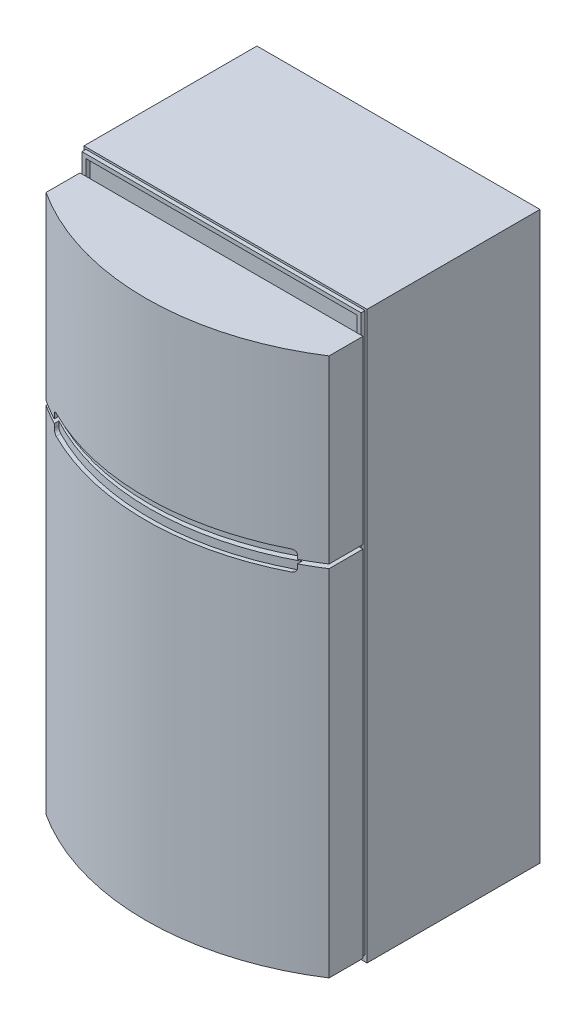
from build123d import *

# Parameters (mm, degrees)
SKETCH1_W               = 900
SKETCH1_H               = 550
BOSS_EXTRUDE1_DEPTH     = 1800
BOSS_EXTRUDE2_START     = 19.05
BOSS_EXTRUDE2_DEPTH     = 1712.976
SKETCH3_W               = 900
SKETCH3_H               = 12.7
CUT_EXTRUDE1_DEPTH      = 1712.976
CUT_EXTRUDE2_REACH      = 2023.869
CUT_EXTRUDE2_END_RADIUS = 816.026540559
SKETCH5_W               = 887.3
SKETCH5_H               = 1774.6
SKETCH5_W_2             = 861.9
SKETCH5_H_2             = 1749.2
EXTRUDE_THIN1_DEPTH     = 12.7
CUT_EXTRUDE3_DEPTH      = 1936.20024806


with BuildPart() as part:
    # Sketch1 → Boss-Extrude1 (new body)
    with BuildSketch(Plane(origin=(0, 0, 0), x_dir=(1, 0, 0), z_dir=(0, 1, 0))):
        Rectangle(SKETCH1_W, SKETCH1_H)
    extrude(amount=BOSS_EXTRUDE1_DEPTH)

    # Sketch6 → Cut-Extrude3 (cut, through all)
    with BuildSketch(Plane.XY.offset(275)):
        Polygon((-302.626047731, 0), (-268.027399007, 13.483618078), (268.027399007, 13.483618078), (302.626047731, 0), align=None)
    extrude(amount=-CUT_EXTRUDE3_DEPTH, mode=Mode.SUBTRACT)


with BuildPart() as body_2:
    # Sketch2 → Boss-Extrude2 (new body)
    with BuildSketch(Plane(origin=(0, 0, 0), x_dir=(1, 0, 0), z_dir=(0, 1, 0)).offset(BOSS_EXTRUDE2_START)):
        with BuildLine():
            Line((-450, -287.7), (450, -287.7))
            Line((450, -287.7), (450, -395.583268728))
            ThreePointArc((450, -395.583268728), (0, -528.402), (-450, -395.583268728))
            Line((-450, -395.583268728), (-450, -287.7))
        make_face()
    extrude(amount=BOSS_EXTRUDE2_DEPTH)

    # Sketch3 → Cut-Extrude1 (cut)
    with BuildSketch(Plane.XY.offset(528.402)):
        with Locations((0, 1152.493299562)):
            Rectangle(SKETCH3_W, SKETCH3_H)
    extrude(amount=-CUT_EXTRUDE1_DEPTH, mode=Mode.SUBTRACT)


with BuildPart() as cut_extrude1_piece_1:
    # of the separate pieces the step leaves, piece 1, a body of its own (cut_extrude1_pieces)
    add(body_2.part.solids().sort_by_distance((-450, 19.05, 395.583268728))[0])


with BuildPart() as cut_extrude1_piece_2:
    # of the separate pieces the step leaves, piece 2, a body of its own (cut_extrude1_pieces)
    add(body_2.part.solids().sort_by_distance((-450, 1158.843299562, 395.583268728))[0])


with BuildPart() as cut_extrude2_tool:
    # Cut-Extrude2: up to this cylinder (the profile starts outside it)
    cut_extrude2_end = Plane(origin=(0, 1152.4933, -300.324540559), z_dir=(0, -1, 0)) * Cylinder(CUT_EXTRUDE2_END_RADIUS, 5680.791081118, mode=Mode.PRIVATE)
    # Sketch4 → Cut-Extrude2 (new, up to the surface)
    with BuildSketch(Plane.XY.offset(528.402), mode=Mode.PRIVATE) as cut_extrude2_sk1:
        with BuildLine():
            Line((-373.8, 1184.243299562), (373.8, 1184.243299562))
            ThreePointArc((373.8, 1184.243299562), (382.780256121, 1180.523555683), (386.5, 1171.543299562))
            Line((386.5, 1171.543299562), (386.5, 1133.443299562))
            ThreePointArc((386.5, 1133.443299562), (382.780256121, 1124.463043441), (373.8, 1120.743299562))
            Line((373.8, 1120.743299562), (-373.8, 1120.743299562))
            ThreePointArc((-373.8, 1120.743299562), (-382.780256121, 1124.463043441), (-386.5, 1133.443299562))
            Line((-386.5, 1133.443299562), (-386.5, 1171.543299562))
            ThreePointArc((-386.5, 1171.543299562), (-382.780256121, 1180.523555683), (-373.8, 1184.243299562))
        make_face()
    cut_extrude2_tool1 = extrude(cut_extrude2_sk1.sketch, amount=-CUT_EXTRUDE2_REACH, mode=Mode.PRIVATE) - cut_extrude2_end
    add(cut_extrude2_tool1.solids().sort_by_distance((0, 1152.4933, 528.402))[0])


with BuildPart() as cut_extrude1_piece_1_1:
    add(cut_extrude1_piece_1.part)

    # Cut-Extrude2: cut by cut_extrude2_tool
    add(cut_extrude2_tool.part, mode=Mode.SUBTRACT)


with BuildPart() as cut_extrude1_piece_2_1:
    add(cut_extrude1_piece_2.part)

    # Cut-Extrude2: cut by cut_extrude2_tool
    add(cut_extrude2_tool.part, mode=Mode.SUBTRACT)


with BuildPart() as body_4:
    # Sketch5 → Extrude-Thin1 (new body)
    with BuildSketch(Plane.XY.offset(275)):
        with Locations((0, 906.35)):
            Rectangle(SKETCH5_W, SKETCH5_H)
        with Locations((0, 906.35)):
            Rectangle(SKETCH5_W_2, SKETCH5_H_2, mode=Mode.SUBTRACT)
    extrude(amount=EXTRUDE_THIN1_DEPTH)


solid = Compound([part.part, cut_extrude1_piece_1_1.part, cut_extrude1_piece_2_1.part, body_4.part])
